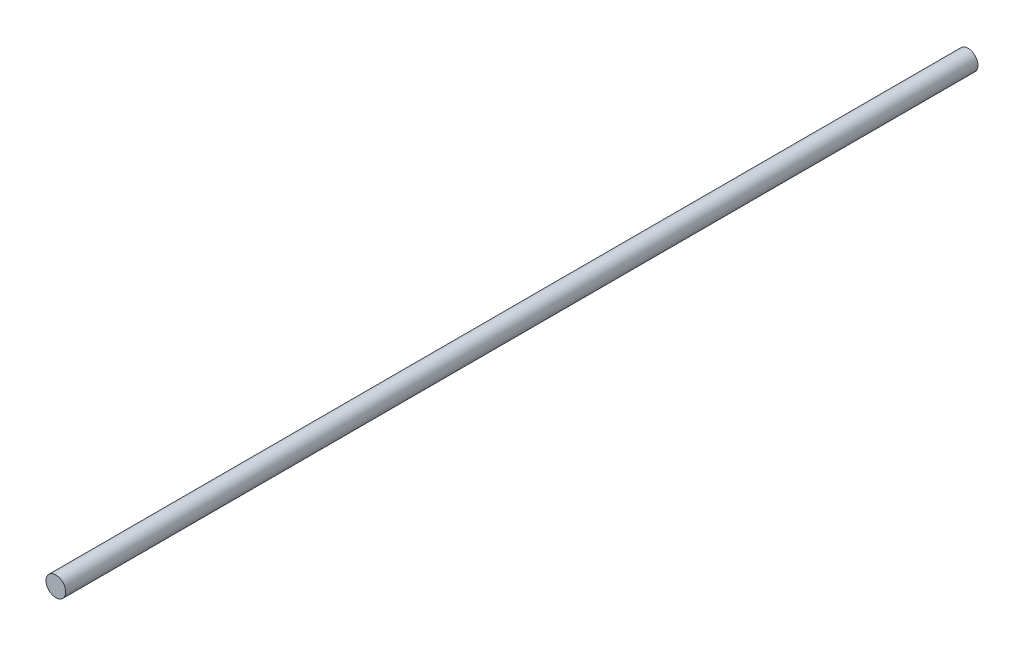
from build123d import *

# Parameters (mm, degrees)
SKETCH1_R           = 4
BOSS_EXTRUDE1_DEPTH = 369.52


with BuildPart() as part:
    # Sketch1 → Boss-Extrude1 (new body)
    with BuildSketch(Plane.XY):
        Circle(SKETCH1_R)
    extrude(amount=BOSS_EXTRUDE1_DEPTH)


solid = part.part
